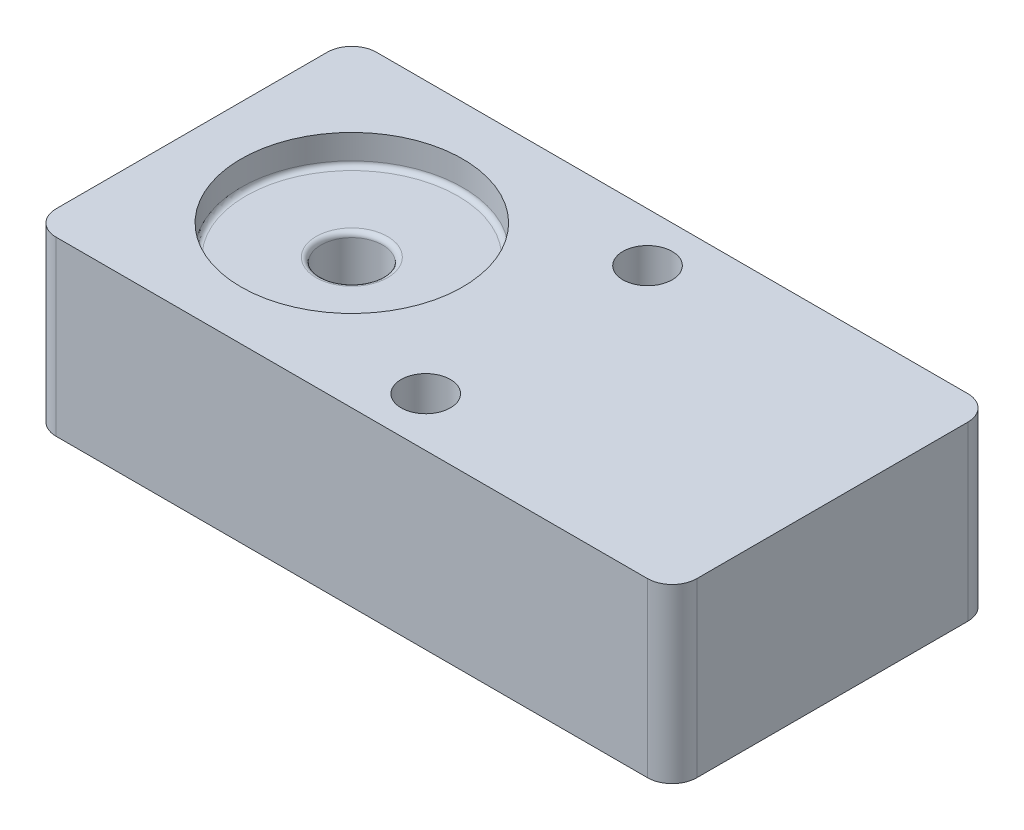
from build123d import *

# Parameters (mm, degrees)
ESQUISSE2_W             = 260
ESQUISSE2_H             = 130
BOSS_EXTRU_2_DEPTH      = 70
ESQUISSE3_R             = 45
ENL_V_MAT_EXTRU_1_DEPTH = 12
CONG_1_R                = 2
ESQUISSE4_R             = 12.5
ENL_V_MAT_EXTRU_2_DEPTH = 38
CONG_2_R                = 2
CONG_3_R                = 2
CONG_4_R                = 10
CONG_5_R                = 10
CONG_6_R                = 10
CONG_7_R                = 10
ESQUISSE6_R             = 10
ENL_V_MAT_EXTRU_3_DEPTH = 71


with BuildPart() as part:
    # Esquisse2 → Boss.-Extru.2 (new body)
    with BuildSketch(Plane(origin=(0, 0, 0), x_dir=(1, 0, 0), z_dir=(0, 1, 0))):
        Rectangle(ESQUISSE2_W, ESQUISSE2_H)
    extrude(amount=BOSS_EXTRU_2_DEPTH)

    # Esquisse3 → Enlèv. mat.-Extru.1 (cut)
    with BuildSketch(Plane(origin=(0, 70, 0), x_dir=(1, 0, 0), z_dir=(0, 1, 0))):
        with Locations((-65, 0)):
            Circle(ESQUISSE3_R)
    extrude(amount=-ENL_V_MAT_EXTRU_1_DEPTH, mode=Mode.SUBTRACT)

    # Congé1
    cong_1_edges = [part.edges().sort_by_distance(p)[0] for p in [
        (-110, 58, 0),
    ]]
    fillet(cong_1_edges, radius=CONG_1_R)

    # Esquisse4 → Enlèv. mat.-Extru.2 (cut)
    with BuildSketch(Plane(origin=(0, 58, 0), x_dir=(1, 0, 0), z_dir=(0, 1, 0))):
        with Locations((-65, 0)):
            Circle(ESQUISSE4_R)
    extrude(amount=-ENL_V_MAT_EXTRU_2_DEPTH, mode=Mode.SUBTRACT)

    # Congé2
    cong_2_edges = [part.edges().sort_by_distance(p)[0] for p in [
        (-77.5, 58, 0),
    ]]
    fillet(cong_2_edges, radius=CONG_2_R)

    # Congé3
    cong_3_edges = [part.edges().sort_by_distance(p)[0] for p in [
        (-77.5, 20, 0),
    ]]
    fillet(cong_3_edges, radius=CONG_3_R)

    # Congé4
    cong_4_edges = [part.edges().sort_by_distance(p)[0] for p in [
        (-130, 35, -65),
    ]]
    fillet(cong_4_edges, radius=CONG_4_R)

    # Congé5
    cong_5_edges = [part.edges().sort_by_distance(p)[0] for p in [
        (-130, 35, 65),
    ]]
    fillet(cong_5_edges, radius=CONG_5_R)

    # Congé6
    cong_6_edges = [part.edges().sort_by_distance(p)[0] for p in [
        (130, 35, 65),
    ]]
    fillet(cong_6_edges, radius=CONG_6_R)

    # Congé7
    cong_7_edges = [part.edges().sort_by_distance(p)[0] for p in [
        (130, 35, -65),
    ]]
    fillet(cong_7_edges, radius=CONG_7_R)

    # Esquisse6 → Enlèv. mat.-Extru.3 (cut, through all)
    with BuildSketch(Plane(origin=(0, 70, 0), x_dir=(1, 0, 0), z_dir=(0, 1, 0))):
        with Locations((10, 45)):
            Circle(ESQUISSE6_R)
        with Locations((10, -45)):
            Circle(ESQUISSE6_R)
    extrude(amount=-ENL_V_MAT_EXTRU_3_DEPTH, mode=Mode.SUBTRACT)


solid = part.part
